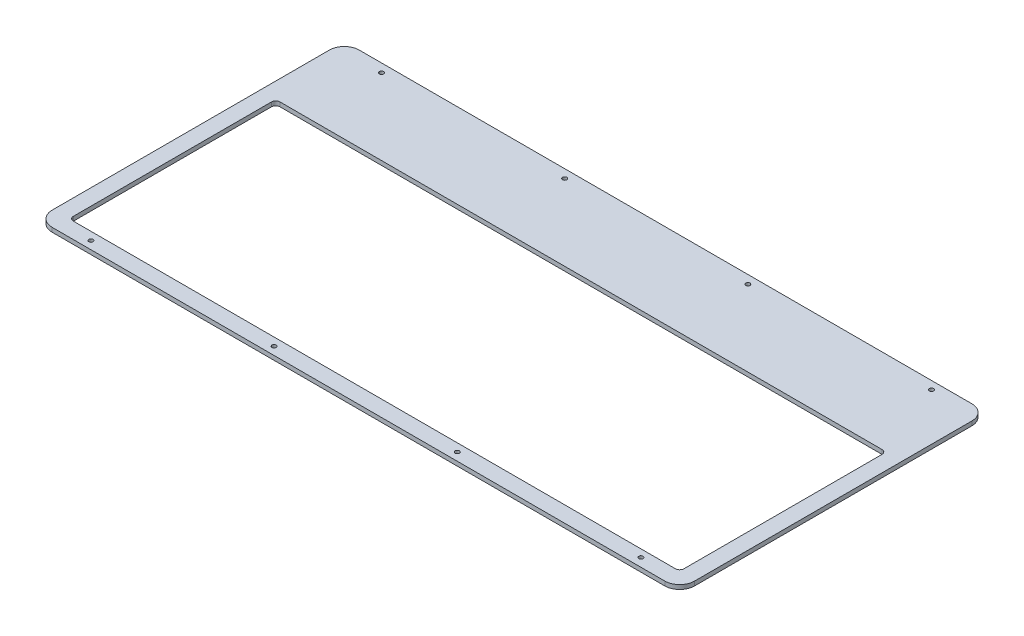
from build123d import *

# Parameters (mm, degrees)
SKETCH1_W           = 350
SKETCH1_H           = 250
BOSS_EXTRUDE1_DEPTH = 2
SKETCH2_OUTSIDE_W   = 438.024
SKETCH2_OUTSIDE_H   = 338.024
SKETCH2_OUTSIDE_R   = 1
CUT_EXTRUDE1_DEPTH  = 10


with BuildPart() as part:
    # Sketch1 → Boss-Extrude1 (new body)
    with BuildSketch(Plane(origin=(0, 0, 0), x_dir=(1, 0, 0), z_dir=(0, 1, 0))):
        with Locations((175, 125)):
            Rectangle(SKETCH1_W, SKETCH1_H)
    extrude(amount=BOSS_EXTRUDE1_DEPTH)

    # Sketch2 outside → Cut-Extrude1 (cut)
    with BuildSketch(Plane(origin=(0, 2, 0), x_dir=(1, 0, 0), z_dir=(0, 1, 0))):
        with Locations((175, 125)):
            Rectangle(SKETCH2_OUTSIDE_W, SKETCH2_OUTSIDE_H)
        with BuildLine():
            Line((20.622413462, 39.237304679), (20.622413462, 169.436764679))
            ThreePointArc((20.622413462, 169.436764679), (22.672665993, 174.386512147), (27.622413462, 176.436764679))
            Line((27.622413462, 176.436764679), (315.321763462, 176.436764679))
            ThreePointArc((315.321763462, 176.436764679), (320.27151093, 174.386512147), (322.321763462, 169.436764679))
            Line((322.321763462, 169.436764679), (322.321763462, 39.237304679))
            ThreePointArc((322.321763462, 39.237304679), (320.27151093, 34.28755721), (315.321763462, 32.237304679))
            Line((315.321763462, 32.237304679), (27.622413462, 32.237304679))
            ThreePointArc((27.622413462, 32.237304679), (22.672665993, 34.28755721), (20.622413462, 39.237304679))
        make_face(mode=Mode.SUBTRACT)
        with Locations((42.122413462, 172.436764679)):
            Circle(SKETCH2_OUTSIDE_R)
        with Locations((128.122413462, 172.436764679)):
            Circle(SKETCH2_OUTSIDE_R)
        with Locations((214.122413462, 172.436764679)):
            Circle(SKETCH2_OUTSIDE_R)
        with Locations((300.122413462, 172.686764679)):
            Circle(SKETCH2_OUTSIDE_R)
        with Locations((300.122413462, 36.237304679)):
            Circle(SKETCH2_OUTSIDE_R)
        with Locations((214.122413462, 35.987304679)):
            Circle(SKETCH2_OUTSIDE_R)
        with Locations((128.122413462, 35.987304679)):
            Circle(SKETCH2_OUTSIDE_R)
        with Locations((42.122413462, 35.987304679)):
            Circle(SKETCH2_OUTSIDE_R)
        with BuildLine():
            Line((312.821763462, 39.737304679), (30.122413462, 39.737304679))
            ThreePointArc((30.122413462, 39.737304679), (28.708199899, 40.323091116), (28.122413462, 41.737304679))
            Line((28.122413462, 41.737304679), (28.122413462, 134.737304679))
            ThreePointArc((28.122413462, 134.737304679), (28.708199899, 136.151518241), (30.122413462, 136.737304679))
            Line((30.122413462, 136.737304679), (312.821763462, 136.737304679))
            ThreePointArc((312.821763462, 136.737304679), (314.235977024, 136.151518241), (314.821763462, 134.737304679))
            Line((314.821763462, 134.737304679), (314.821763462, 41.737304679))
            ThreePointArc((314.821763462, 41.737304679), (314.235977024, 40.323091116), (312.821763462, 39.737304679))
        make_face()
    extrude(amount=-CUT_EXTRUDE1_DEPTH, mode=Mode.SUBTRACT)


solid = part.part
